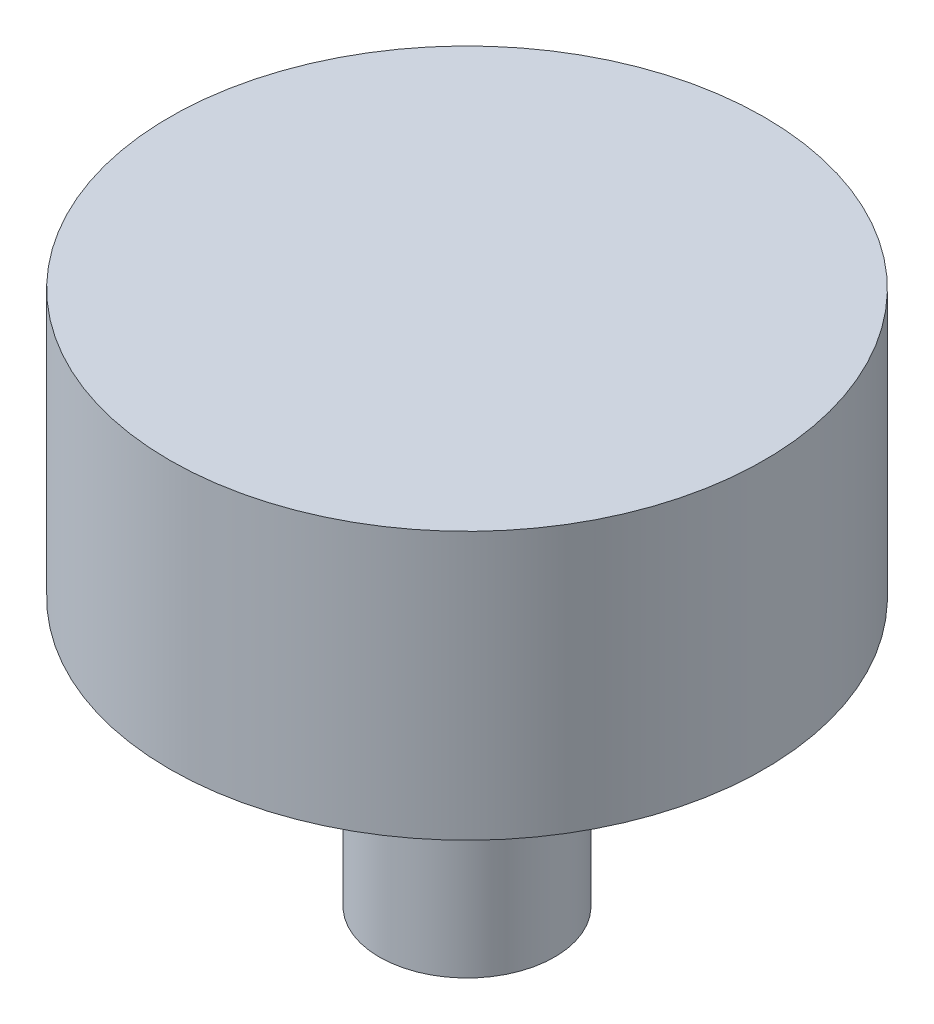
from build123d import *

# Parameters (mm, degrees)
SKETCH1_R           = 2.95
SKETCH1_R_2         = 2.2
BOSS_EXTRUDE1_DEPTH = 9
SKETCH2_R           = 10
BOSS_EXTRUDE2_DEPTH = 9


with BuildPart() as part:
    # Sketch1 → Boss-Extrude1 (new body)
    with BuildSketch(Plane(origin=(0, 0, 0), x_dir=(1, 0, 0), z_dir=(0, 1, 0))):
        Circle(SKETCH1_R)
        Circle(SKETCH1_R_2, mode=Mode.SUBTRACT)
    extrude(amount=BOSS_EXTRUDE1_DEPTH)

    # Sketch2 → Boss-Extrude2 (add)
    with BuildSketch(Plane(origin=(0, 9, 0), x_dir=(1, 0, 0), z_dir=(0, 1, 0))):
        Circle(SKETCH2_R)
    extrude(amount=BOSS_EXTRUDE2_DEPTH)


solid = part.part
